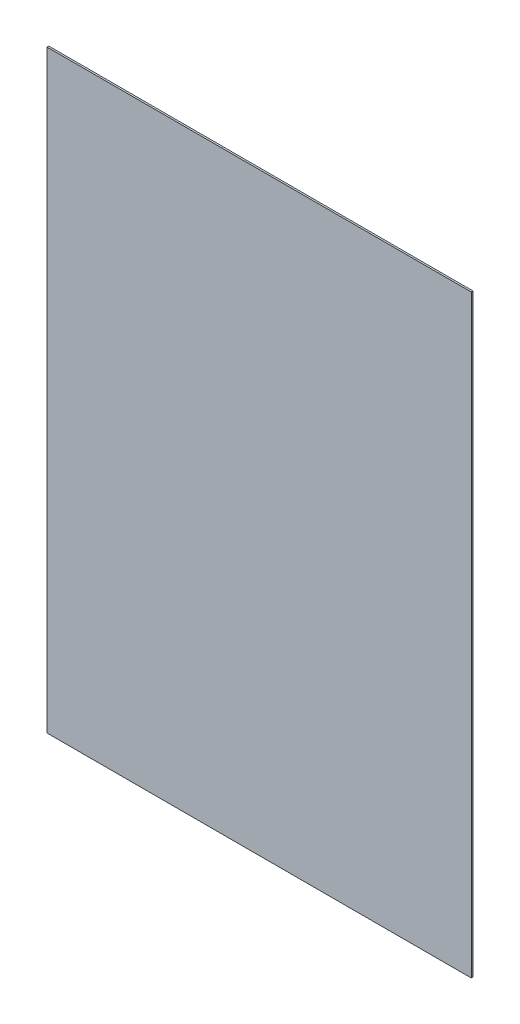
from build123d import *

# Parameters (mm, degrees)
SKETCH1_W           = 762
SKETCH1_H           = 1066.8
BOSS_EXTRUDE1_DEPTH = 3.175


with BuildPart() as part:
    # Sketch1 → Boss-Extrude1 (new body)
    with BuildSketch(Plane.XY):
        Rectangle(SKETCH1_W, SKETCH1_H)
    extrude(amount=BOSS_EXTRUDE1_DEPTH)


solid = part.part
